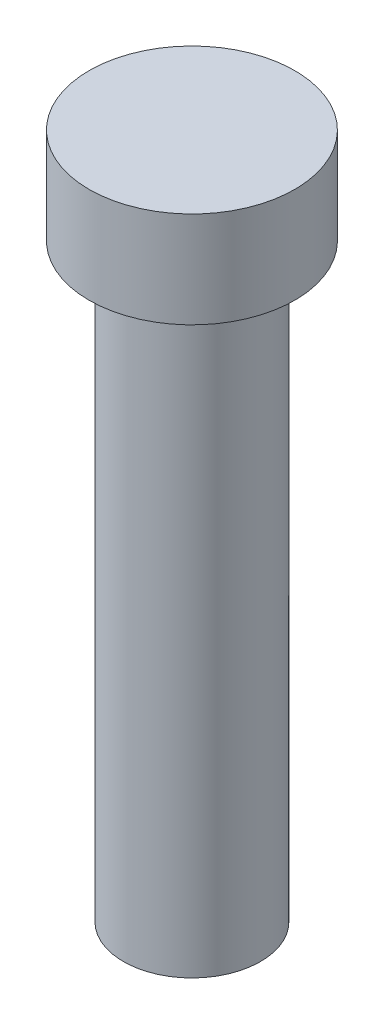
from build123d import *

# Parameters (mm, degrees)
SKETCH1_R           = 7.5
BOSS_EXTRUDE1_DEPTH = 7
SKETCH3_R           = 5
BOSS_EXTRUDE2_DEPTH = 43


with BuildPart() as part:
    # Sketch1 → Boss-Extrude1 (new body)
    with BuildSketch(Plane(origin=(0, 0, 0), x_dir=(1, 0, 0), z_dir=(0, 1, 0))):
        Circle(SKETCH1_R)
    extrude(amount=BOSS_EXTRUDE1_DEPTH)

    # Sketch3 → Boss-Extrude2 (add)
    with BuildSketch(Plane.XZ):
        Circle(SKETCH3_R)
    extrude(amount=BOSS_EXTRUDE2_DEPTH)


solid = part.part
